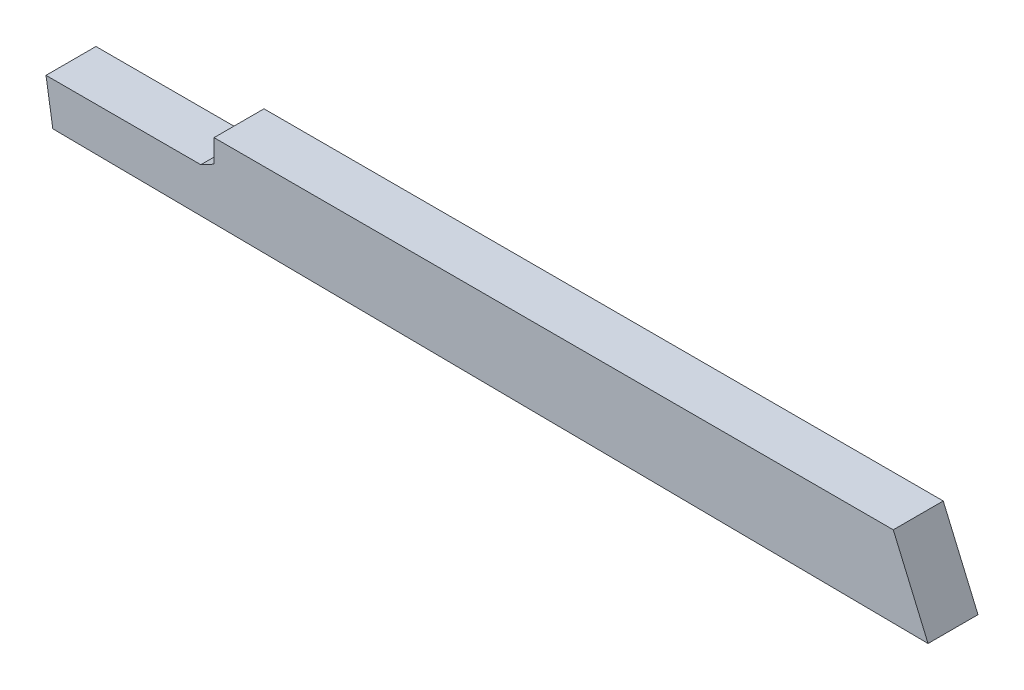
from build123d import *

# Parameters (mm, degrees)
BOSS_EXTRUDE1_DEPTH = 2.54


with BuildPart() as part:
    # Sketch1 → Boss-Extrude1 (new body)
    with BuildSketch(Plane.XY):
        Polygon((0, 0), (34.544, 0), (36.312290702, -4.124935973), (-8.199614436, -3.710718555), (-8.545710911, -1.528189456), (-0.671710911, -1.528189456), (0, -1.1684), align=None)
    extrude(amount=BOSS_EXTRUDE1_DEPTH)


solid = part.part
